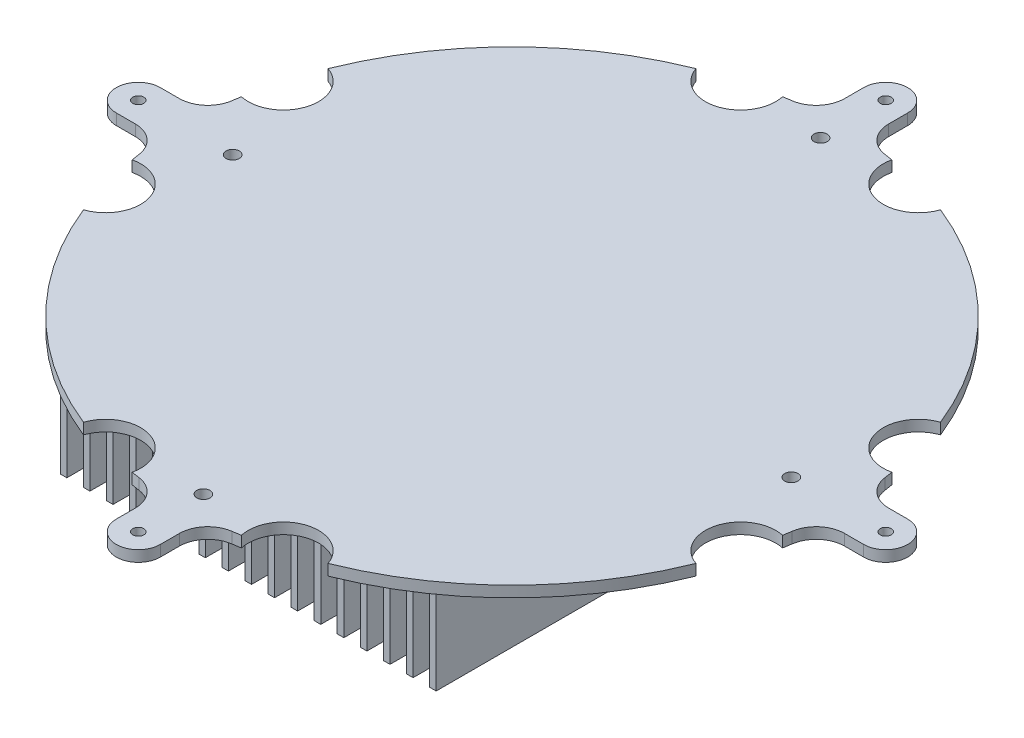
from build123d import *

# Parameters (mm, degrees)
SKETCH3_R           = 2.5
BOSS_EXTRUDE4_DEPTH = 5
SKETCH4_W           = 3
SKETCH4_H           = 240
BOSS_EXTRUDE5_DEPTH = 40
SKETCH7_R           = 3
CUT_EXTRUDE1_DEPTH  = 10
CUT_EXTRUDE2_DEPTH  = 10


with BuildPart() as part:
    # Sketch3 → Boss-Extrude4 (new body)
    with BuildSketch(Plane(origin=(0, 0, 0), x_dir=(1, 0, 0), z_dir=(0, 1, 0))):
        with BuildLine():
            Line((161.369142032, 10), (170, 10))
            ThreePointArc((170, 10), (180, 0), (170, -10))
            Line((170, -10), (161.369142032, -10))
            ThreePointArc((161.369142032, -10), (152.849946816, -13.180462695), (148.499210458, -21.165644172))
            ThreePointArc((148.499210458, -21.165644172), (106.066017178, -106.066017178), (21.165644172, -148.499210458))
            ThreePointArc((21.165644172, -148.499210458), (13.180462695, -152.849946816), (10, -161.369142032))
            Line((10, -161.369142032), (10, -170))
            ThreePointArc((10, -170), (0, -180), (-10, -170))
            Line((-10, -170), (-10, -161.369142032))
            ThreePointArc((-10, -161.369142032), (-13.180462695, -152.849946816), (-21.165644172, -148.499210458))
            ThreePointArc((-21.165644172, -148.499210458), (-106.066017178, -106.066017178), (-148.499210458, -21.165644172))
            ThreePointArc((-148.499210458, -21.165644172), (-152.849946816, -13.180462695), (-161.369142032, -10))
            Line((-161.369142032, -10), (-170, -10))
            ThreePointArc((-170, -10), (-180, 0), (-170, 10))
            Line((-170, 10), (-161.369142032, 10))
            ThreePointArc((-161.369142032, 10), (-152.849946816, 13.180462695), (-148.499210458, 21.165644172))
            ThreePointArc((-148.499210458, 21.165644172), (-106.066017178, 106.066017178), (-21.165644172, 148.499210458))
            ThreePointArc((-21.165644172, 148.499210458), (-13.180462695, 152.849946816), (-10, 161.369142032))
            Line((-10, 161.369142032), (-10, 170))
            ThreePointArc((-10, 170), (0, 180), (10, 170))
            Line((10, 170), (10, 161.369142032))
            ThreePointArc((10, 161.369142032), (13.180462695, 152.849946816), (21.165644172, 148.499210458))
            ThreePointArc((21.165644172, 148.499210458), (106.066017178, 106.066017178), (148.499210458, 21.165644172))
            ThreePointArc((148.499210458, 21.165644172), (152.849946816, 13.180462695), (161.369142032, 10))
        make_face()
        with Locations((0, 170)):
            Circle(SKETCH3_R, mode=Mode.SUBTRACT)
        with Locations((170, 0)):
            Circle(SKETCH3_R, mode=Mode.SUBTRACT)
        with Locations((0, -170)):
            Circle(SKETCH3_R, mode=Mode.SUBTRACT)
        with Locations((-170, 0)):
            Circle(SKETCH3_R, mode=Mode.SUBTRACT)
    extrude(amount=-BOSS_EXTRUDE4_DEPTH)

    # Sketch4 → Boss-Extrude5 (add)
    with BuildSketch(Plane.XZ.offset(5)):
        Rectangle(SKETCH4_W, SKETCH4_H)
        with Locations((10.5, 0)):
            Rectangle(SKETCH4_W, SKETCH4_H)
        with Locations((21, 0)):
            Rectangle(SKETCH4_W, SKETCH4_H)
        with Locations((31.5, 0)):
            Rectangle(SKETCH4_W, SKETCH4_H)
        with Locations((42, 0)):
            Rectangle(SKETCH4_W, SKETCH4_H)
        with Locations((52.5, 0)):
            Rectangle(SKETCH4_W, SKETCH4_H)
        with Locations((63, 0)):
            Rectangle(SKETCH4_W, SKETCH4_H)
        with Locations((73.5, 0)):
            Rectangle(SKETCH4_W, SKETCH4_H)
        with Locations((84, 0)):
            Rectangle(SKETCH4_W, SKETCH4_H)
        with Locations((-84, 0)):
            Rectangle(SKETCH4_W, SKETCH4_H)
        with Locations((-73.5, 0)):
            Rectangle(SKETCH4_W, SKETCH4_H)
        with Locations((-63, 0)):
            Rectangle(SKETCH4_W, SKETCH4_H)
        with Locations((-52.5, 0)):
            Rectangle(SKETCH4_W, SKETCH4_H)
        with Locations((-42, 0)):
            Rectangle(SKETCH4_W, SKETCH4_H)
        with Locations((-31.5, 0)):
            Rectangle(SKETCH4_W, SKETCH4_H)
        with Locations((-21, 0)):
            Rectangle(SKETCH4_W, SKETCH4_H)
        with Locations((-10.5, 0)):
            Rectangle(SKETCH4_W, SKETCH4_H)
    extrude(amount=BOSS_EXTRUDE5_DEPTH)

    # Sketch7 → Cut-Extrude1 (cut)
    with BuildSketch(Plane(origin=(0, 0, 0), x_dir=(1, 0, 0), z_dir=(0, 1, 0))):
        with Locations((-127.088241501, 0)):
            Circle(SKETCH7_R)
        with Locations((0, 140.377871213)):
            Circle(SKETCH7_R)
        with Locations((0, -140.377871213)):
            Circle(SKETCH7_R)
        with Locations((127.088241501, 0)):
            Circle(SKETCH7_R)
    extrude(amount=-CUT_EXTRUDE1_DEPTH, mode=Mode.SUBTRACT)

    # Sketch8 → Cut-Extrude2 (cut)
    with BuildSketch(Plane(origin=(0, 0, 0), x_dir=(1, 0, 0), z_dir=(0, 1, 0))):
        with BuildLine():
            ThreePointArc((24.849797215, -147.927305047), (40.464884917, -144.438890499), (55.619572151, -139.307082353))
            ThreePointArc((55.619572151, -139.307082353), (36.148630526, -129.032075513), (24.849797215, -147.927305047))
        make_face()
        with BuildLine():
            ThreePointArc((-55.619572151, -139.307082353), (-36.148630526, -129.032075513), (-24.849797215, -147.927305047))
            ThreePointArc((-24.849797215, -147.927305047), (-40.464884917, -144.438890499), (-55.619572151, -139.307082353))
        make_face()
        with BuildLine():
            ThreePointArc((-139.307082353, -55.619572151), (-129.032075513, -36.148630526), (-147.927305047, -24.849797215))
            ThreePointArc((-147.927305047, -24.849797215), (-144.438890499, -40.464884917), (-139.307082353, -55.619572151))
        make_face()
        with BuildLine():
            ThreePointArc((-139.307082353, 55.619572151), (-129.032075513, 36.148630526), (-147.927305047, 24.849797215))
            ThreePointArc((-147.927305047, 24.849797215), (-144.438890499, 40.464884917), (-139.307082353, 55.619572151))
        make_face()
        with BuildLine():
            ThreePointArc((-55.619572151, 139.307082353), (-36.148630526, 129.032075513), (-24.849797215, 147.927305047))
            ThreePointArc((-24.849797215, 147.927305047), (-40.464884917, 144.438890499), (-55.619572151, 139.307082353))
        make_face()
        with BuildLine():
            ThreePointArc((55.619572151, 139.307082353), (36.148630526, 129.032075513), (24.849797215, 147.927305047))
            ThreePointArc((24.849797215, 147.927305047), (40.464884917, 144.438890499), (55.619572151, 139.307082353))
        make_face()
        with BuildLine():
            ThreePointArc((139.307082353, 55.619572151), (129.032075513, 36.148630526), (147.927305047, 24.849797215))
            ThreePointArc((147.927305047, 24.849797215), (144.438890499, 40.464884917), (139.307082353, 55.619572151))
        make_face()
        with BuildLine():
            ThreePointArc((139.307082353, -55.619572151), (129.032075513, -36.148630526), (147.927305047, -24.849797215))
            ThreePointArc((147.927305047, -24.849797215), (144.438890499, -40.464884917), (139.307082353, -55.619572151))
        make_face()
    extrude(amount=-CUT_EXTRUDE2_DEPTH, mode=Mode.SUBTRACT)


solid = part.part
